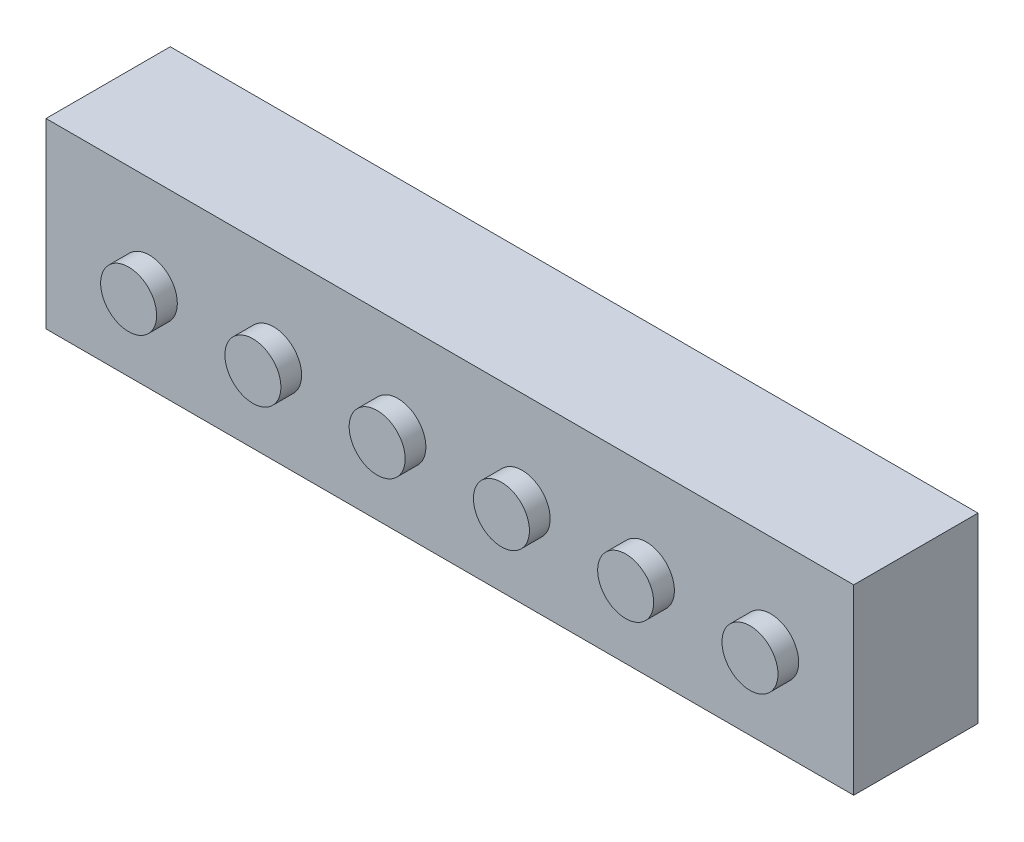
from build123d import *

# Parameters (mm, degrees)
SKETCH1_W           = 390
SKETCH1_H           = 88
BOSS_EXTRUDE1_DEPTH = 60
SKETCH2_R           = 13.520117845
BOSS_EXTRUDE2_DEPTH = 10
LPATTERN1_COUNT     = 6
LPATTERN1_PITCH     = 60


with BuildPart() as part:
    # Sketch1 → Boss-Extrude1 (new body)
    with BuildSketch(Plane.XY):
        with Locations((2.535, 19.375)):
            Rectangle(SKETCH1_W, SKETCH1_H)
    extrude(amount=BOSS_EXTRUDE1_DEPTH)

    # Sketch2 → Boss-Extrude2 (add)
    with BuildSketch(Plane.XY.offset(60)):
        with Locations((-142.569495457, 17.704999413)):
            Circle(SKETCH2_R)
    boss_extrude2 = extrude(amount=BOSS_EXTRUDE2_DEPTH)

    # LPattern1: Boss-Extrude2 ×6
    with Locations(*[(i * LPATTERN1_PITCH, 0, 0) for i in range(1, LPATTERN1_COUNT)]):
        add(boss_extrude2)


solid = part.part
